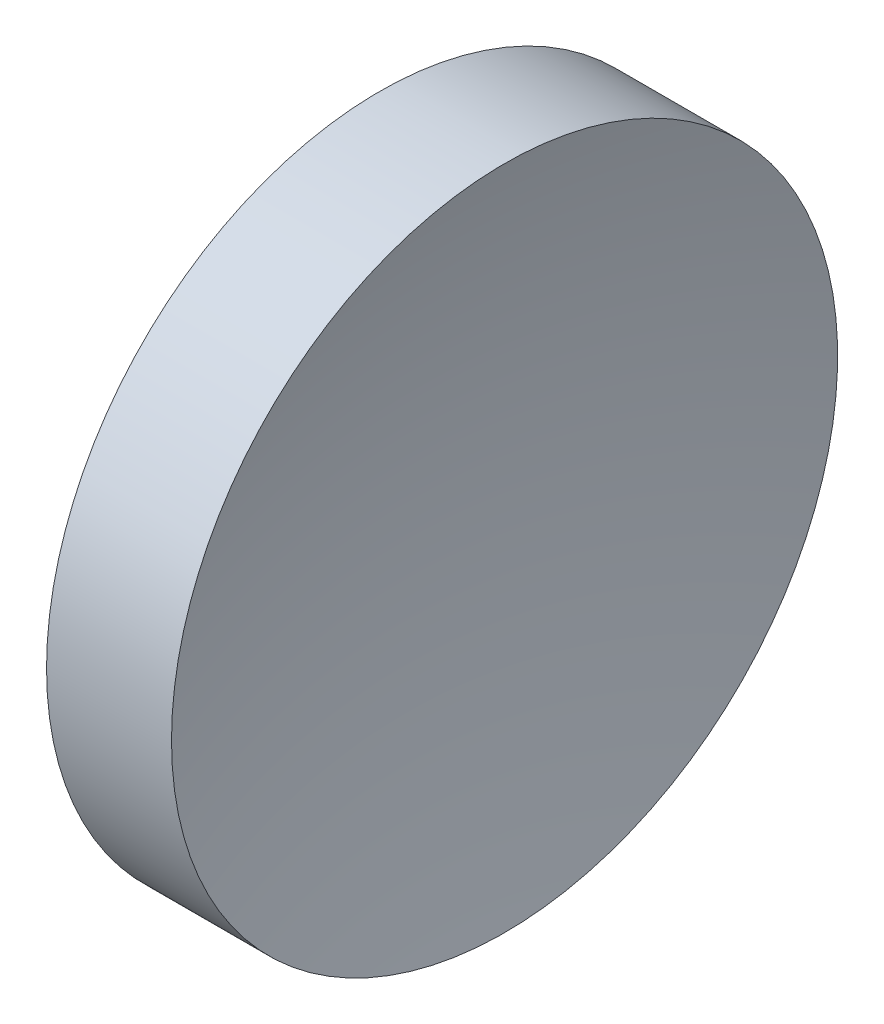
from build123d import *


with BuildPart() as part:
    # 草图1 → 旋转1 (revolve)
    with BuildSketch(Plane(origin=(0, 0, 0), x_dir=(1, 0, 0), z_dir=(0, 1, 0)), mode=Mode.PRIVATE) as revolve_1_sk:
        with BuildLine():
            Line((0, 0), (6.25, 0))
            ThreePointArc((6.25, 0), (7.07328352, 12.805424953), (9.529578165, 25.4))
            Line((9.529578165, 25.4), (0, 25.4))
            Line((0, 25.4), (0, 0))
        make_face()
    revolve(revolve_1_sk.sketch.rotate(Axis((0, 0, 0), (1, 0, 0)), 180), axis=Axis((0, 0, 0), (1, 0, 0)))  # turned: the seam where the file's is


solid = part.part
